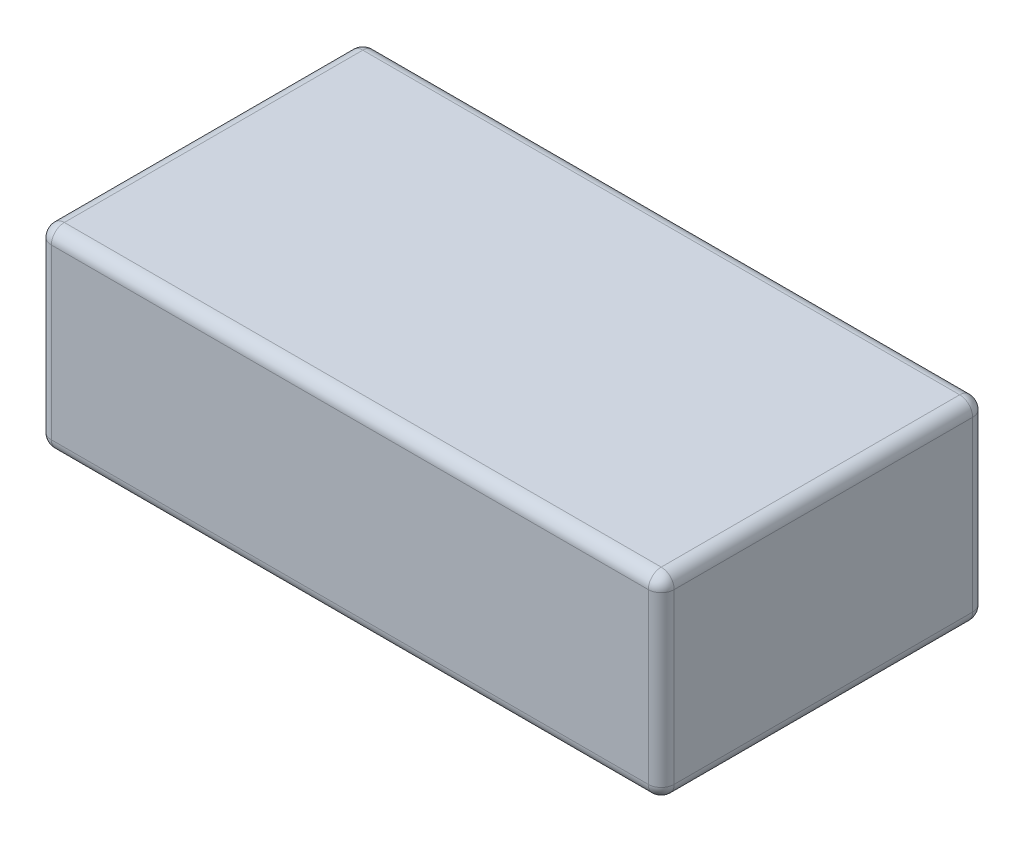
from build123d import *

# Parameters (mm, degrees)
SKETCH1_W           = 48
SKETCH1_H           = 25
BOSS_EXTRUDE1_DEPTH = 15
FILLET1_R           = 1


with BuildPart() as part:
    # Sketch1 → Boss-Extrude1 (new body)
    with BuildSketch(Plane(origin=(0, 0, 0), x_dir=(1, 0, 0), z_dir=(0, 1, 0))):
        Rectangle(SKETCH1_W, SKETCH1_H)
    extrude(amount=BOSS_EXTRUDE1_DEPTH)

    # Fillet1
    fillet1_edges = [part.edges().sort_by_distance(p)[0] for p in [
        (-24, 15, 0),
        (0, 15, 12.5),
        (24, 15, 0),
        (0, 0, 12.5),
        (-24, 0, 0),
        (0, 0, -12.5),
        (24, 0, 0),
        (24, 7.5, 12.5),
        (-24, 7.5, 12.5),
        (-24, 7.5, -12.5),
        (24, 7.5, -12.5),
        (0, 15, -12.5),
    ]]
    fillet(fillet1_edges, radius=FILLET1_R)


solid = part.part
